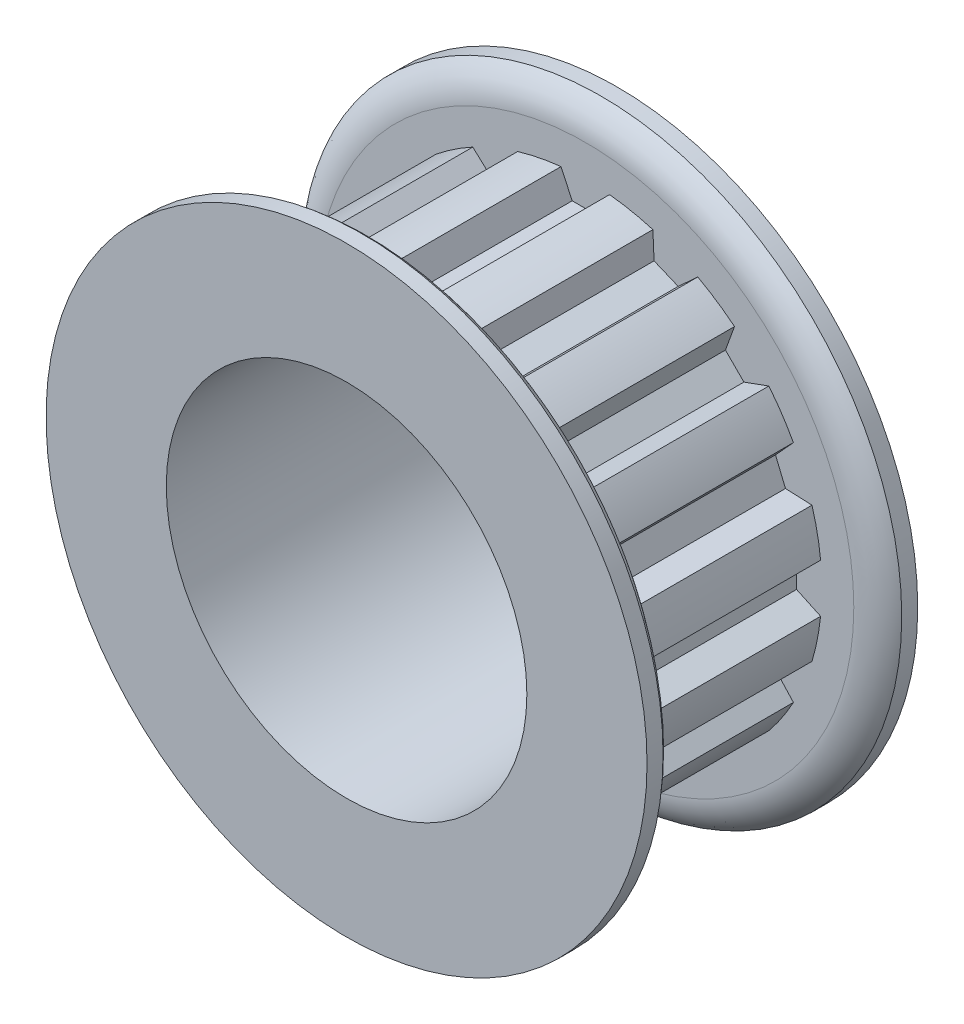
from build123d import *

# Parameters (mm, degrees)
CUT_EXTRUDE1_START = 2.2987
CUT_EXTRUDE1_DEPTH = 10.922
CIRPATTERN1_COUNT  = 16
SKETCH8_R          = 9.525
CUT_EXTRUDE2_DEPTH = 27.618169923


with BuildPart() as part:
    # Sketch2 → Revolve1 (revolve)
    with BuildSketch(Plane(origin=(0, 0, 0), x_dir=(0, 0, -1), z_dir=(1, 0, 0)), mode=Mode.PRIVATE) as revolve1_sk:
        with BuildLine():
            Line((-3.9878, 3.175), (10.3124, 3.175))
            Line((10.3124, 3.175), (10.3124, 15.875))
            Line((10.3124, 15.875), (9.46785, 15.875))
            ThreePointArc((9.46785, 15.875), (8.846219323, 15.130824061), (8.6233, 14.187145354))
            Line((8.6233, 14.187145354), (8.6233, 12.499290707))
            Line((8.6233, 12.499290707), (-2.2987, 12.499290707))
            Line((-2.2987, 12.499290707), (-2.2987, 14.187145354))
            ThreePointArc((-2.2987, 14.187145354), (-2.521619323, 15.130824061), (-3.14325, 15.875))
            Line((-3.14325, 15.875), (-3.9878, 15.875))
            Line((-3.9878, 15.875), (-3.9878, 8.7376))
            Line((-3.9878, 8.7376), (-3.9878, 3.175))
        make_face()
    revolve(revolve1_sk.sketch.rotate(Axis((0, 0, 10.3124), (0, 0, -1)), 90), axis=Axis((0, 0, 10.3124), (0, 0, -1)))

    # Sketch3 → Cut-Extrude1 (cut)
    with BuildSketch(Plane.XY.offset(CUT_EXTRUDE1_START)):
        with BuildLine():
            Line((-0.690489274, 11.1633), (0.690489274, 11.1633))
            Line((0.690489274, 11.1633), (1.2827, 12.4333))
            ThreePointArc((1.2827, 12.4333), (0, 12.499290707), (-1.2827, 12.4333))
            Line((-1.2827, 12.4333), (-0.690489274, 11.1633))
        make_face()
    cut_extrude1 = extrude(amount=-CUT_EXTRUDE1_DEPTH, mode=Mode.SUBTRACT)

    # CirPattern1: Cut-Extrude1 ×16 about axis
    cirpattern1_axis = Axis((0, 0, 0), (0, 0, 1))
    for i in range(1, CIRPATTERN1_COUNT):
        add(cut_extrude1.rotate(cirpattern1_axis, i * 360 / CIRPATTERN1_COUNT), mode=Mode.SUBTRACT)

    # Sketch8 → Cut-Extrude2 (cut, through all)
    with BuildSketch(Plane.XY.offset(3.9878)):
        Circle(SKETCH8_R)
    extrude(amount=-CUT_EXTRUDE2_DEPTH, mode=Mode.SUBTRACT)


solid = part.part
